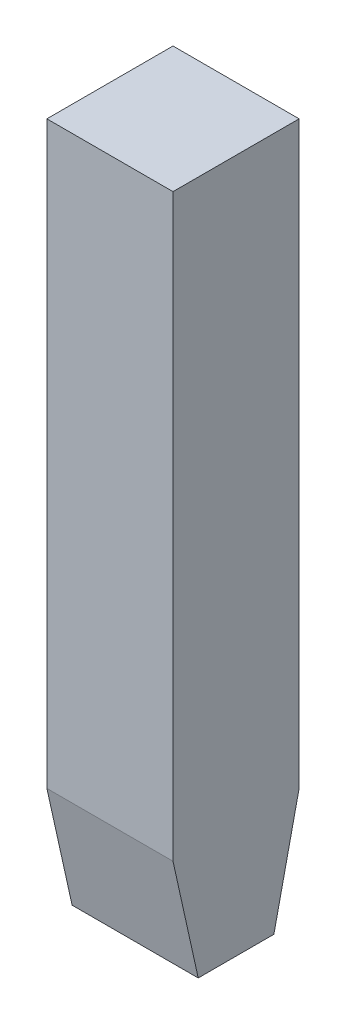
from build123d import *

# Parameters (mm, degrees)
PLAT_W                       = 55
PLAT_H                       = 10
EL_MENT_M_CANO_SOUD_1_DEPTH  = 10
ENL_V_MAT_EXTRU_1_DEPTH      = 6
ENL_V_MAT_EXTRU_1_DEPTH_BACK = 6


with BuildPart() as part:
    # plat → Elément mécano-soudé1 (new body)
    with BuildSketch(Plane.YZ.offset(-5)):
        Rectangle(PLAT_W, PLAT_H)
    extrude(amount=EL_MENT_M_CANO_SOUD_1_DEPTH)

    # Esquisse2 → Enlèv. mat.-Extru.1 (cut, two sides)
    with BuildSketch(Plane(origin=(0, 0, 0), x_dir=(0, 0, -1), z_dir=(1, 0, 0))) as enl_v_mat_extru_1_sk:
        Polygon((-3, -27.5), (-5, -18.478582993), (-5, -27.5), align=None)
        Polygon((5, -27.5), (5, -18.478582993), (3, -27.5), align=None)
    extrude(amount=ENL_V_MAT_EXTRU_1_DEPTH, mode=Mode.SUBTRACT)
    extrude(enl_v_mat_extru_1_sk.sketch, amount=-ENL_V_MAT_EXTRU_1_DEPTH_BACK, mode=Mode.SUBTRACT)


solid = part.part
